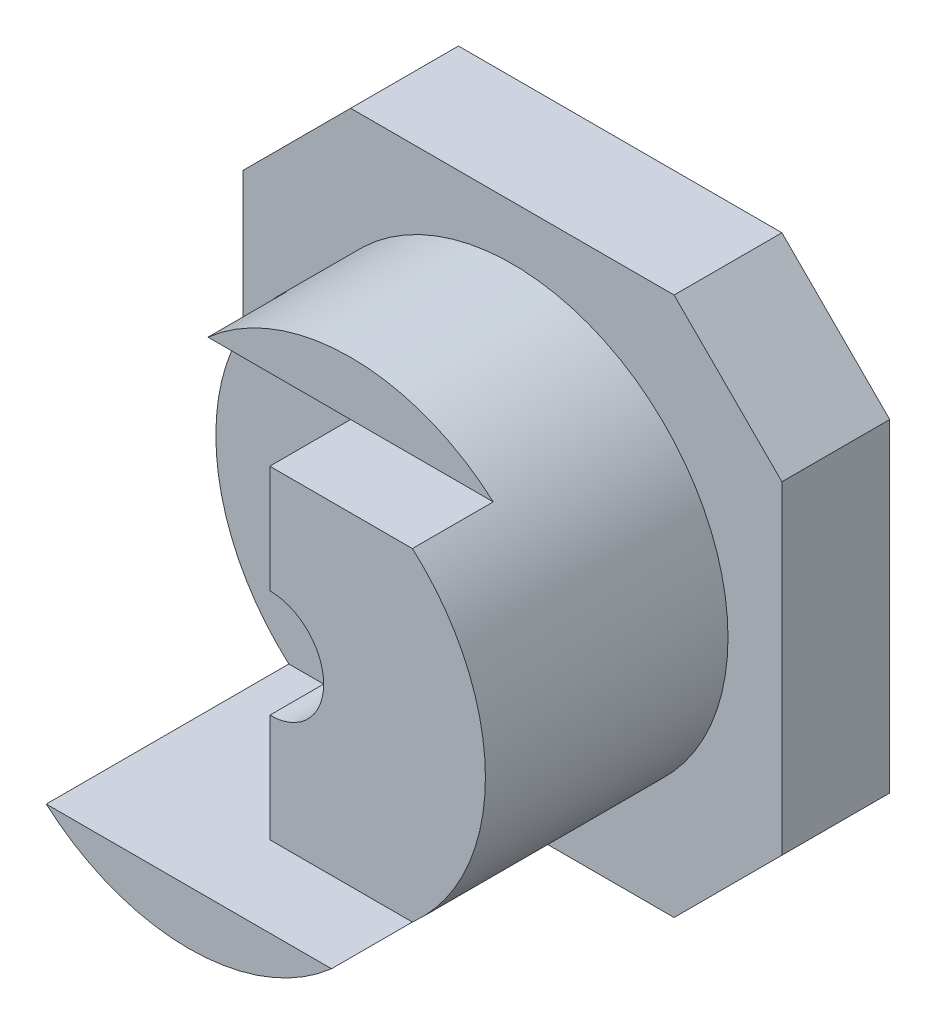
from build123d import *

# Parameters (mm, degrees)
SKETCH1_R           = 1
BOSS_EXTRUDE1_DEPTH = 2
SKETCH2_R           = 4
SKETCH2_R_2         = 1
BOSS_EXTRUDE2_DEPTH = 6
CUT_EXTRUDE2_DEPTH  = 8
SKETCH5_W           = 3
SKETCH5_H           = 6
CUT_EXTRUDE3_DEPTH  = 16


with BuildPart() as part:
    # Sketch1 → Boss-Extrude1 (new body)
    with BuildSketch(Plane.XY):
        Polygon((-5, 3), (-3, 5), (3, 5), (5, 3), (5, -3), (3, -5), (-3, -5), (-5, -3), align=None)
        Circle(SKETCH1_R, mode=Mode.SUBTRACT)
    extrude(amount=BOSS_EXTRUDE1_DEPTH)

    # Sketch2 → Boss-Extrude2 (add)
    with BuildSketch(Plane.XY.offset(2)):
        Circle(SKETCH2_R)
        Circle(SKETCH2_R_2, mode=Mode.SUBTRACT)
    extrude(amount=BOSS_EXTRUDE2_DEPTH)

    # Sketch4 → Cut-Extrude2 (cut, symmetric)
    with BuildSketch(Plane(origin=(0, 0, 0), x_dir=(0, 0, -1), z_dir=(1, 0, 0))):
        Polygon((-8, -3), (-6.5, -3), (-6.5, 3), (-5, 3), (-5, 4), (-8, 4), align=None)
    extrude(amount=CUT_EXTRUDE2_DEPTH, both=True, mode=Mode.SUBTRACT)

    # Sketch5 → Cut-Extrude3 (cut)
    with BuildSketch(Plane(origin=(0, 0, 0), x_dir=(0, 0, -1), z_dir=(1, 0, 0))):
        with Locations((-5, 0)):
            Rectangle(SKETCH5_W, SKETCH5_H)
    extrude(amount=-CUT_EXTRUDE3_DEPTH, mode=Mode.SUBTRACT)


solid = part.part
